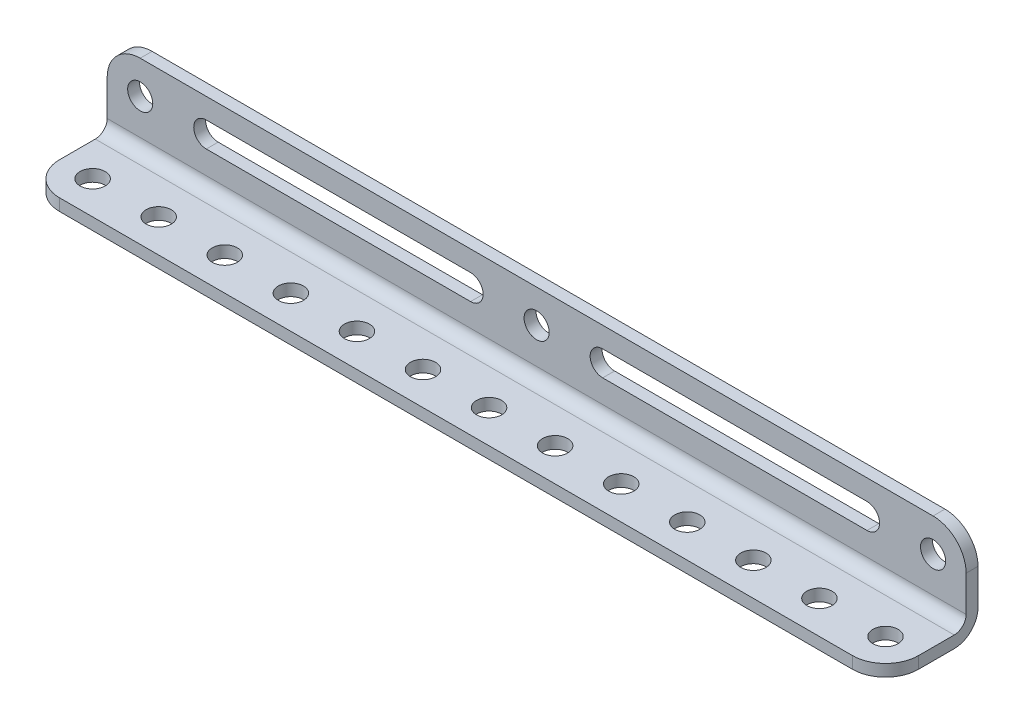
from build123d import *

# Parameters (mm, degrees)
EXTRUDE_THIN1_DEPTH = 82.55
SKETCH2_R           = 2.413
CUT_EXTRUDE1_DEPTH  = 3.286
LPATTERN1_COUNT     = 13
LPATTERN1_PITCH     = 12.7
FILLET1_R           = 6.35
SKETCH3_R           = 2.413
CUT_EXTRUDE2_DEPTH  = 3.286
LPATTERN2_COUNT     = 3
LPATTERN2_PITCH     = 76.2
CUT_EXTRUDE3_DEPTH  = 3.286


with BuildPart() as part:
    # Sketch1 → Extrude-Thin1 (new body, symmetric)
    with BuildSketch(Plane(origin=(0, 0, 0), x_dir=(0, 0, -1), z_dir=(1, 0, 0))):
        with BuildLine():
            Line((0, 0), (13.208, 0))
            ThreePointArc((13.208, 0), (16.440892204, 1.339107796), (17.78, 4.572))
            Line((17.78, 4.572), (17.78, 17.78))
            Line((17.78, 17.78), (15.494, 17.78))
            Line((15.494, 17.78), (15.494, 4.572))
            ThreePointArc((15.494, 4.572), (14.824446102, 2.955553898), (13.208, 2.286))
            Line((13.208, 2.286), (0, 2.286))
            Line((0, 2.286), (0, 0))
        make_face()
    extrude(amount=EXTRUDE_THIN1_DEPTH, both=True)

    # Sketch2 → Cut-Extrude1 (cut, through all)
    with BuildSketch(Plane(origin=(0, 2.286, 0), x_dir=(1, 0, 0), z_dir=(0, 1, 0))):
        with Locations((-76.2, 6.35)):
            Circle(SKETCH2_R)
    cut_extrude1 = extrude(amount=-CUT_EXTRUDE1_DEPTH, mode=Mode.SUBTRACT)

    # LPattern1: Cut-Extrude1 ×13
    with Locations(*[(i * LPATTERN1_PITCH, 0, 0) for i in range(1, LPATTERN1_COUNT)]):
        add(cut_extrude1, mode=Mode.SUBTRACT)

    # Fillet1
    fillet1_edges = [part.edges().sort_by_distance(p)[0] for p in [
        (82.55, 1.143, 0),
        (82.55, 17.78, -16.637),
        (-82.55, 1.143, 0),
        (-82.55, 17.78, -16.637),
    ]]
    fillet(fillet1_edges, radius=FILLET1_R)

    # Sketch3 → Cut-Extrude2 (cut, through all)
    with BuildSketch(Plane.XY.offset(-15.494)):
        with Locations((-76.2, 11.43)):
            Circle(SKETCH3_R)
    cut_extrude2 = extrude(amount=-CUT_EXTRUDE2_DEPTH, mode=Mode.SUBTRACT)

    # LPattern2: Cut-Extrude2 ×3
    with Locations(*[(i * LPATTERN2_PITCH, 0, 0) for i in range(1, LPATTERN2_COUNT)]):
        add(cut_extrude2, mode=Mode.SUBTRACT)

    # Sketch4 → Cut-Extrude3 (cut, through all)
    with BuildSketch(Plane.XY.offset(-15.494)):
        with BuildLine():
            Line((-63.5, 13.843), (-12.7, 13.843))
            ThreePointArc((-12.7, 13.843), (-10.287, 11.43), (-12.7, 9.017))
            Line((-12.7, 9.017), (-63.5, 9.017))
            ThreePointArc((-63.5, 9.017), (-65.913, 11.43), (-63.5, 13.843))
        make_face()
        with BuildLine():
            Line((63.5, 13.843), (12.7, 13.843))
            ThreePointArc((12.7, 13.843), (10.287, 11.43), (12.7, 9.017))
            Line((12.7, 9.017), (63.5, 9.017))
            ThreePointArc((63.5, 9.017), (65.913, 11.43), (63.5, 13.843))
        make_face()
    extrude(amount=-CUT_EXTRUDE3_DEPTH, mode=Mode.SUBTRACT)


solid = part.part
